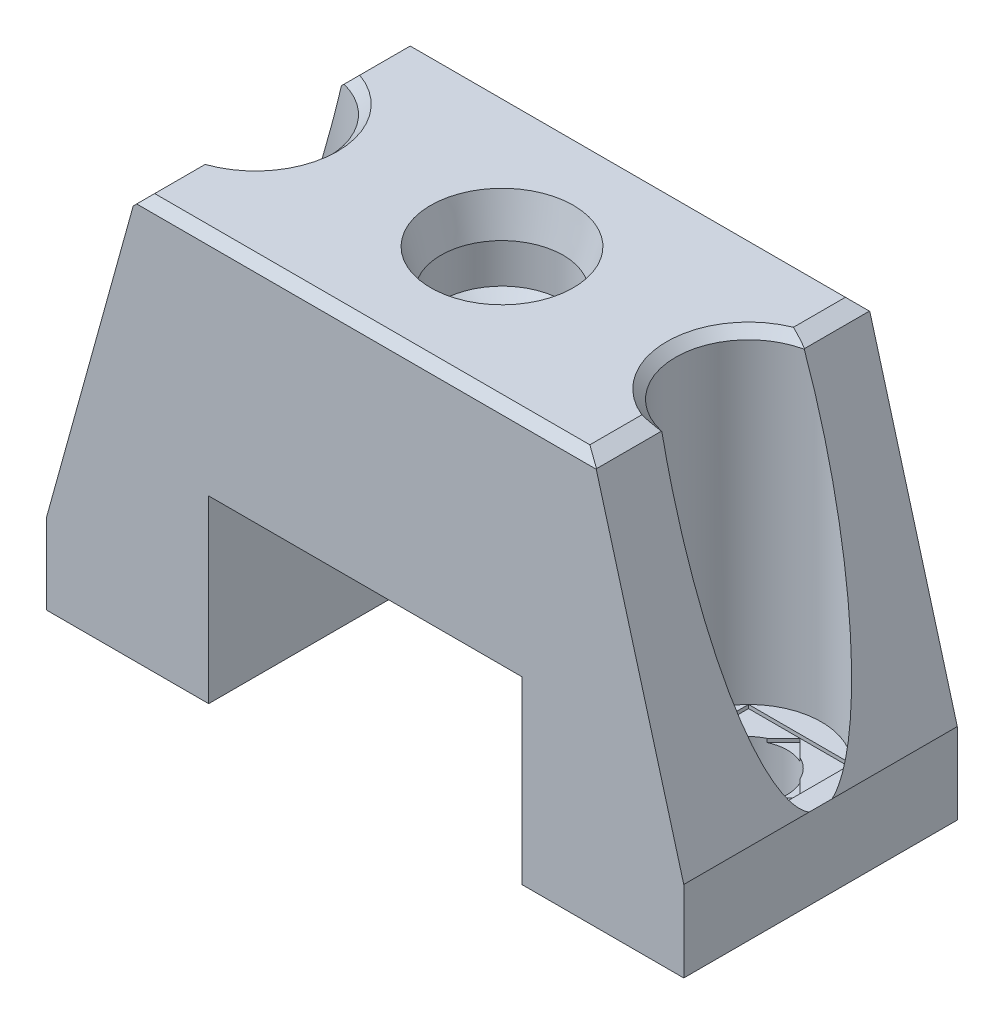
from build123d import *
from OCP.BRepFilletAPI import BRepFilletAPI_MakeChamfer

# Parameters (mm, degrees)
SKETCH3_W           = 35.4
SKETCH3_H           = 15.2
SKETCH3_R           = 2.15
SKETCH3_R_2         = 6.5
BOSS_EXTRUDE1_DEPTH = 11.55
SKETCH4_W           = 17.4
SKETCH4_H           = 15.2
SKETCH4_W_2         = 15.4
SKETCH4_H_2         = 13.2
BOSS_EXTRUDE2_DEPTH = 1
SKETCH5_W           = 9
SKETCH5_H           = 15.2
SKETCH5_R           = 2.15
BOSS_EXTRUDE3_DEPTH = 11.5
SKETCH6_R           = 4.05
CUT_EXTRUDE1_DEPTH  = 18.05
CUT_EXTRUDE4_DEPTH  = 27.033295988
CHAMFER1_SIZE       = 0.5
CHAMFER1_SIZE2      = 0.717613884
SKETCH10_W          = 5.727564928
SKETCH10_H          = 5.727564928
CUT_EXTRUDE5_DEPTH  = 0.2
CUT_EXTRUDE6_DEPTH  = 0.2


with BuildPart() as part:
    # Sketch1 → Revolve1 (revolve)
    with BuildSketch(Plane.XY, mode=Mode.PRIVATE) as revolve1_sk:
        Polygon((3.15, 0.7051349), (2.5, 0.25), (2.5, 0), (6.5, 0), (6.5, 11.55), (3.967375816, 11.55), (3.4, 9.432524629), (3.4, 7.240352815), (1.7, 6.05), (1.7, 2.55), (3.15, 2.55), align=None)
    revolve(revolve1_sk.sketch.rotate(Axis((0, 0, 0), (0, 1, 0)), 90), axis=Axis((0, 0, 0), (0, 1, 0)))

    # Sketch3 → Boss-Extrude1 (add)
    with BuildSketch(Plane.XZ):
        Rectangle(SKETCH3_W, SKETCH3_H)
        with Locations(Location((13.7, 0, 0), (0, 0, 270))):
            Circle(SKETCH3_R, mode=Mode.SUBTRACT)
        with Locations(Location((-13.7, 0, 0), (0, 0, 270))):
            Circle(SKETCH3_R, mode=Mode.SUBTRACT)
        Circle(SKETCH3_R_2, mode=Mode.SUBTRACT)
    extrude(amount=-BOSS_EXTRUDE1_DEPTH)

    # Sketch4 → Boss-Extrude2 (add)
    with BuildSketch(Plane.XZ):
        Rectangle(SKETCH4_W, SKETCH4_H)
        Rectangle(SKETCH4_W_2, SKETCH4_H_2, mode=Mode.SUBTRACT)
    extrude(amount=BOSS_EXTRUDE2_DEPTH)

    # Sketch5 → Boss-Extrude3 (add)
    with BuildSketch(Plane.XZ):
        with Locations((13.2, 0)):
            Rectangle(SKETCH5_W, SKETCH5_H)
        with Locations(Location((13.7, 0, 0), (0, 0, 270))):
            Circle(SKETCH5_R, mode=Mode.SUBTRACT)
        with Locations((-13.2, 0)):
            Rectangle(SKETCH5_W, SKETCH5_H)
        with Locations(Location((-13.7, 0, 0), (0, 0, 270))):
            Circle(SKETCH5_R, mode=Mode.SUBTRACT)
    extrude(amount=BOSS_EXTRUDE3_DEPTH)

    # Sketch6 → Cut-Extrude1 (cut)
    with BuildSketch(Plane(origin=(0, 11.55, 0), x_dir=(1, 0, 0), z_dir=(0, 1, 0))):
        with Locations((-13.7, 0)):
            Circle(SKETCH6_R)
        with Locations((13.7, 0)):
            Circle(SKETCH6_R)
    extrude(amount=-CUT_EXTRUDE1_DEPTH, mode=Mode.SUBTRACT)

    # Sketch8 → Cut-Extrude4 (cut, through all)
    with BuildSketch(Plane(origin=(0, 0, -7.6), x_dir=(-1, 0, 0), z_dir=(0, 0, -1))):
        Polygon((-17.7, -6.5), (-12.7, 11.55), (-17.7, 11.55), align=None)
        Polygon((17.7, 11.55), (17.7, -6.5), (12.7, 11.55), align=None)
    extrude(amount=-CUT_EXTRUDE4_DEPTH, mode=Mode.SUBTRACT)

    # Chamfer1: one chamfer whose edges measure the first distance from different faces: ONE call of the kernel's chamfer builder (chamfer() names one face for all edges)
    chamfer1_edges_1 = [part.edges().sort_by_distance(p)[0] for p in [
        (13.7, -11.5, 2.15),
        (17.7, -11.5, 0),
        (13.2, -11.5, -7.6),
        (8.7, -11.5, 0),
        (13.2, -11.5, 7.6),
        (-13.7, -11.5, 2.15),
        (-17.7, -11.5, 0),
        (-13.2, -11.5, 7.6),
        (-8.7, -11.5, 0),
        (-13.2, -11.5, -7.6),
        (-9.65, 11.55, 0),
        (0, 11.55, -7.6),
        (9.65, 11.55, 0),
        (0, 11.55, 7.6),
    ]]
    chamfer1_edges_2 = [part.edges().sort_by_distance(p)[0] for p in [
        (-12.7, 11.55, 5.762300945),
        (-12.7, 11.55, -5.762300945),
    ]]
    chamfer1_side_2 = [part.faces().sort_by_distance(p)[0] for p in [
        (-9.353993243, 11.55, 0),
    ]]
    chamfer1_edges_3 = [part.edges().sort_by_distance(p)[0] for p in [
        (12.7, 11.55, -5.762300945),
    ]]
    chamfer1_side_3 = [part.faces().sort_by_distance(p)[0] for p in [
        (15.4479971, 1.629730468, -5.405864047),
    ]]
    chamfer1_edges_4 = [part.edges().sort_by_distance(p)[0] for p in [
        (12.7, 11.55, 5.762300945),
    ]]
    chamfer1_side_4 = [part.faces().sort_by_distance(p)[0] for p in [
        (15.4479971, 1.629730468, 5.405864047),
    ]]
    chamfer1 = BRepFilletAPI_MakeChamfer(part.part.solid().wrapped)
    for e in chamfer1_edges_1:
        chamfer1.Add(CHAMFER1_SIZE, e.wrapped)
    for e in chamfer1_edges_2:
        chamfer1.Add(CHAMFER1_SIZE, CHAMFER1_SIZE2, e.wrapped, chamfer1_side_2[0].wrapped)  # the first distance lies on this face
    for e in chamfer1_edges_3:
        chamfer1.Add(CHAMFER1_SIZE, CHAMFER1_SIZE2, e.wrapped, chamfer1_side_3[0].wrapped)  # the first distance lies on this face
    for e in chamfer1_edges_4:
        chamfer1.Add(CHAMFER1_SIZE, CHAMFER1_SIZE2, e.wrapped, chamfer1_side_4[0].wrapped)  # the first distance lies on this face
    add(Compound.cast(chamfer1.Shape()), mode=Mode.REPLACE)

    # Sketch10 → Cut-Extrude5 (cut)
    with BuildSketch(Plane(origin=(0, -6.5, 0), x_dir=(1, 0, 0), z_dir=(0, 1, 0))):
        with Locations((-13.7, 0)):
            Rectangle(SKETCH10_W, SKETCH10_H)
        with Locations((13.7, 0)):
            Rectangle(SKETCH10_W, SKETCH10_H)
    extrude(amount=-CUT_EXTRUDE5_DEPTH, mode=Mode.SUBTRACT)

    # Sketch11 → Cut-Extrude6 (cut)
    with BuildSketch(Plane(origin=(0, -6.7, 0), x_dir=(1, 0, 0), z_dir=(0, 1, 0))):
        Polygon((-16.563782464, 0), (-13.7, -2.863782464), (-10.836217536, 0), (-13.7, 2.863782464), align=None)
        Polygon((13.7, 2.863782464), (10.836217536, 0), (13.7, -2.863782464), (16.563782464, 0), align=None)
    extrude(amount=-CUT_EXTRUDE6_DEPTH, mode=Mode.SUBTRACT)


solid = part.part
